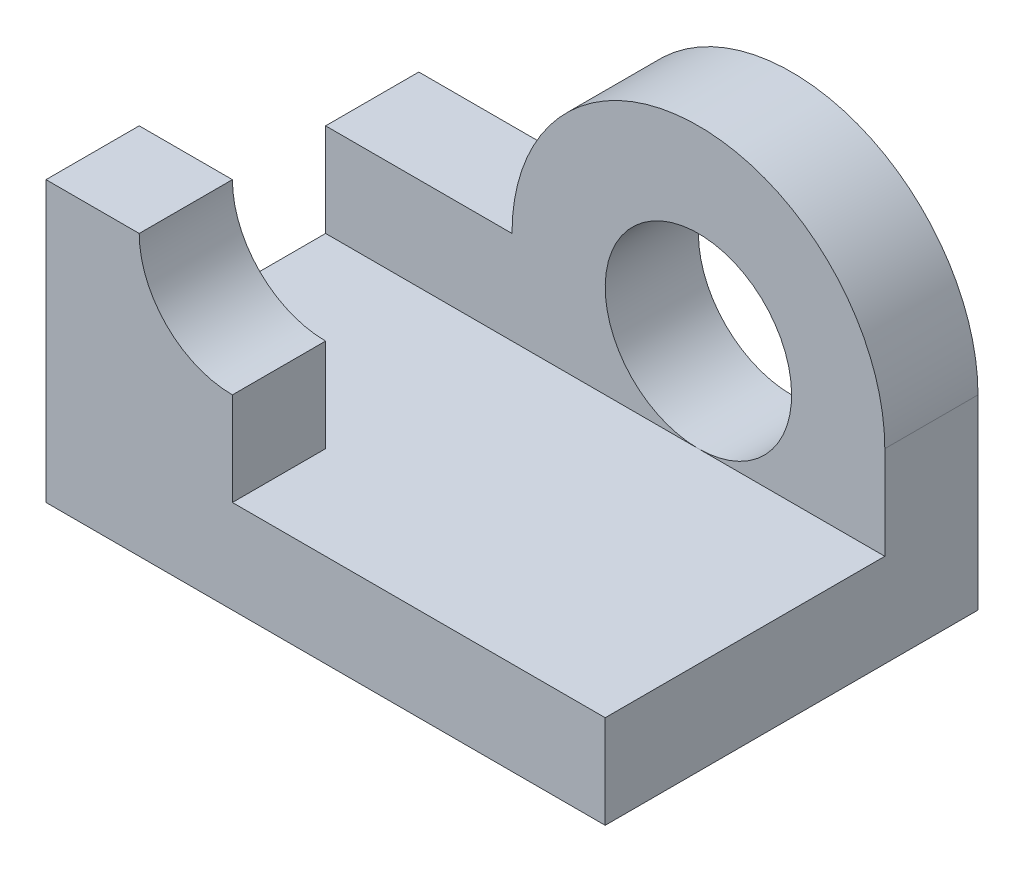
from build123d import *

# Parameters (mm, degrees)
SKETCH_1_R      = 5
EXTRUDE_1_DEPTH = 5
SKETCH_1_6_W    = 30
SKETCH_1_6_H    = 5
EXTRUDE_3_DEPTH = 20
EXTRUDE_START   = 15
EXTRUDE_4_DEPTH = 5


with BuildPart() as part:
    # 草圖1 → 填料-伸長1 (new body)
    with BuildSketch(Plane.XY):
        with BuildLine():
            ThreePointArc((10, 10), (0, 20), (-10, 10))
            Line((-10, 10), (-20, 10))
            Line((-20, 10), (-20, 0))
            Line((-20, 0), (10, 0))
            Line((10, 0), (10, 10))
        make_face()
        with Locations((0, 10)):
            Circle(SKETCH_1_R, mode=Mode.SUBTRACT)
    extrude(amount=EXTRUDE_1_DEPTH)

    # 草圖1<6> → 填料-伸長3 (add)
    with BuildSketch(Plane.XY):
        with Locations((-5, 2.5)):
            Rectangle(SKETCH_1_6_W, SKETCH_1_6_H)
    extrude(amount=EXTRUDE_3_DEPTH)

    # 草圖1<7> → 填料-伸長4 (add)
    with BuildSketch(Plane.XY.offset(EXTRUDE_START)):
        with BuildLine():
            Line((-10, 5), (-10, 10))
            ThreePointArc((-10, 10), (-13.535533906, 11.464466094), (-15, 15))
            Line((-15, 15), (-20, 15))
            Line((-20, 15), (-20, 5))
            Line((-20, 5), (-10, 5))
        make_face()
    extrude(amount=EXTRUDE_4_DEPTH)


solid = part.part
